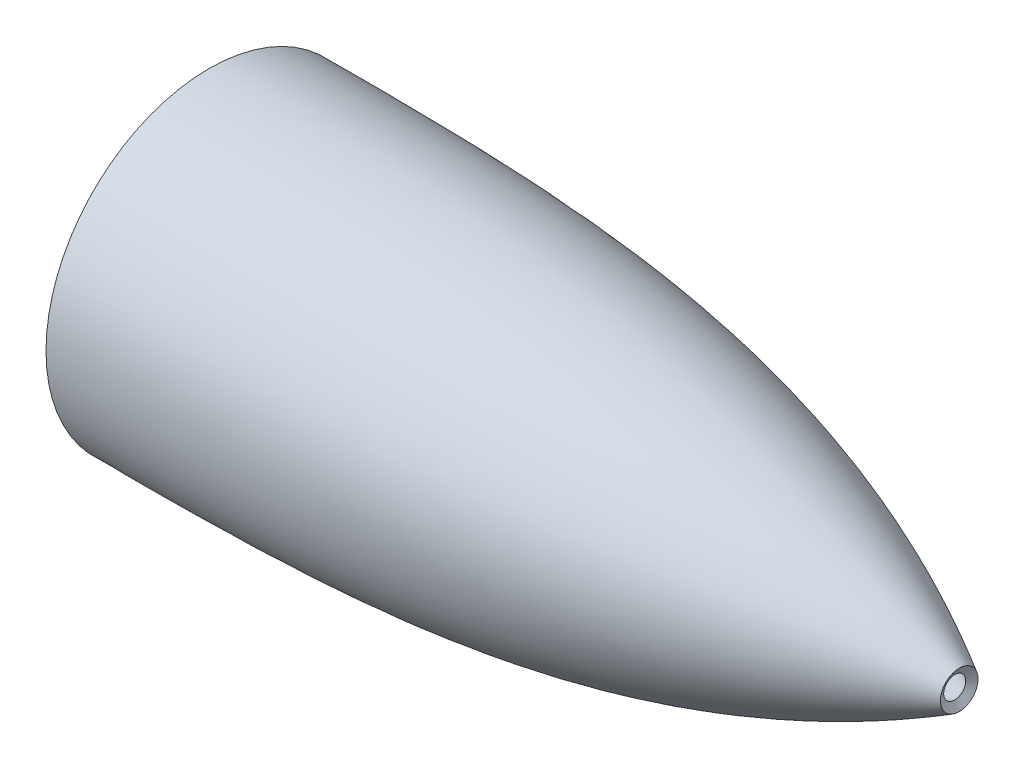
from build123d import *


with BuildPart() as part:
    # Schizzo1 → Rivoluzione1 (revolve)
    with BuildSketch(Plane.XY):
        with BuildLine():
            Line((-2001.1, 6.1), (-1998.599808029, 10.430016179))
            add(Edge.make_bspline(
                [(-2414.200898397, 90.288489786), (-2378.399521511, 90.294922555), (-2342.597697709, 90.317439544), (-2297.893329192, 88.621294249), (-2288.954846707, 88.19600693), (-2271.083855348, 87.130446278), (-2262.149531122, 86.490013213), (-2235.368732308, 84.18351643), (-2217.594895047, 82.135489923), (-2182.253606336, 76.723264297), (-2164.686176447, 73.358927674), (-2145.061820389, 68.687595735), (-2142.882911625, 68.156172047), (-2138.53622029, 67.07013029), (-2132.030277364, 65.405676356), (-2125.567063857, 63.633925586), (-2112.698663775, 59.944713987), (-2104.197146895, 57.290840825), (-2078.931374991, 48.729629696), (-2062.406548595, 42.221068159), (-2030.012249193, 27.558302677), (-2014.142590625, 19.404564692), (-1998.599808029, 10.430016179)],
                knots=[0, 0, 0, 0, 0.25, 0.25, 0.3125, 0.3125, 0.375, 0.375, 0.5, 0.5, 0.625, 0.625, 0.640625, 0.640625, 0.65625, 0.6875, 0.6875, 0.75, 0.75, 0.875, 0.875, 1, 1, 1, 1], degree=3))
            Line((-2414.200898397, 90.288489786), (-2414.2, 85.288489867))
            add(Edge.make_bspline(
                [(-2414.2, 85.288489867), (-2276.5, 85.313231717), (-2138.8, 85.609272083), (-2001.1, 6.1)],
                knots=[0.07354021, 0.07354021, 0.07354021, 0.07354021, 0.915776383, 0.915776383, 0.915776383, 0.915776383], degree=3))
        make_face()
    revolve(axis=Axis((-2491.00200492, 0, 0), (1, 0, 0)))


solid = part.part
